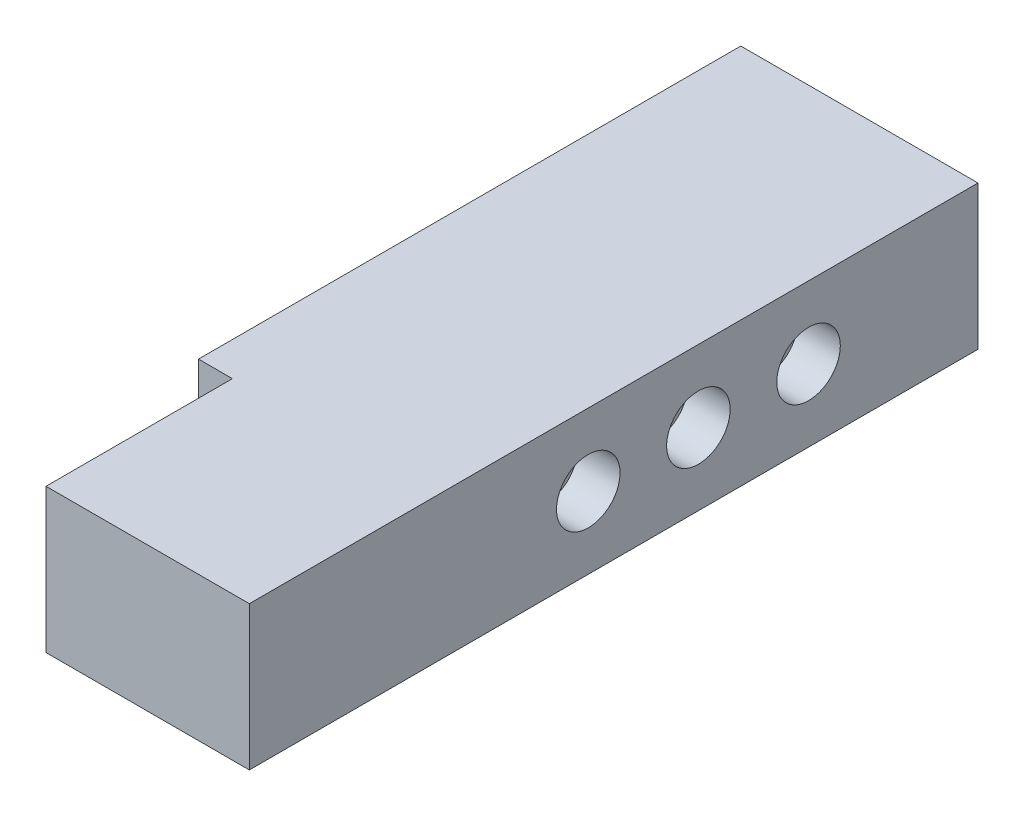
from build123d import *

# Parameters (mm, degrees)
SKETCH1_W           = 35.56
SKETCH1_H           = 21.59
BOSS_EXTRUDE1_DEPTH = 81.28
SKETCH2_W           = 30.48
SKETCH2_H           = 21.59
BOSS_EXTRUDE2_DEPTH = 27.94
SKETCH3_R           = 4.7625
CUT_EXTRUDE1_DEPTH  = 6.35
SKETCH4_R           = 4.7625
CUT_EXTRUDE2_DEPTH  = 6.35


with BuildPart() as part:
    # Sketch1 → Boss-Extrude1 (new body)
    with BuildSketch(Plane.XY):
        with Locations((17.78, 10.795)):
            Rectangle(SKETCH1_W, SKETCH1_H)
    extrude(amount=BOSS_EXTRUDE1_DEPTH)

    # Sketch2 → Boss-Extrude2 (add)
    with BuildSketch(Plane.XY.offset(81.28)):
        with Locations((20.32, 10.795)):
            Rectangle(SKETCH2_W, SKETCH2_H)
    extrude(amount=BOSS_EXTRUDE2_DEPTH)

    # Sketch3 → Cut-Extrude1 (cut)
    with BuildSketch(Plane(origin=(35.56, 0, 0), x_dir=(0, 0, -1), z_dir=(1, 0, 0))):
        with Locations((-25.4, 10.795)):
            Circle(SKETCH3_R)
        with Locations((-41.91, 10.795)):
            Circle(SKETCH3_R)
        with Locations((-58.42, 10.795)):
            Circle(SKETCH3_R)
    extrude(amount=-CUT_EXTRUDE1_DEPTH, mode=Mode.SUBTRACT)

    # Sketch4 → Cut-Extrude2 (cut)
    with BuildSketch(Plane.ZY):
        with Locations((33.655, 10.795)):
            Circle(SKETCH4_R)
        with Locations((50.165, 10.795)):
            Circle(SKETCH4_R)
    extrude(amount=-CUT_EXTRUDE2_DEPTH, mode=Mode.SUBTRACT)


solid = part.part
